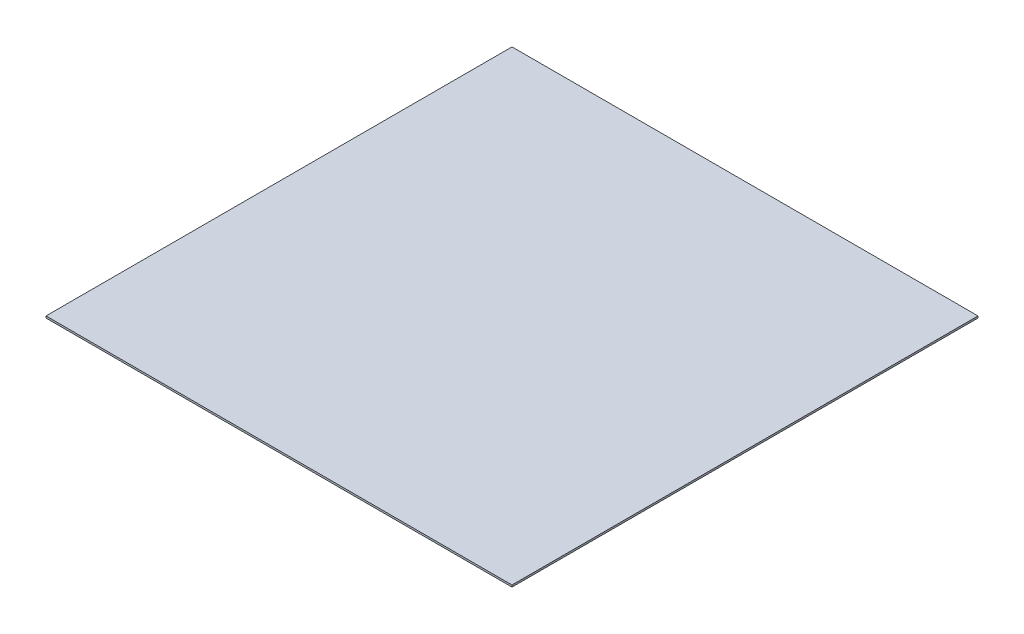
from build123d import *

# Parameters (mm, degrees)
SKETCH1_W           = 5000
SKETCH1_H           = 5000
BOSS_EXTRUDE1_DEPTH = 20


with BuildPart() as part:
    # Sketch1 → Boss-Extrude1 (new body)
    with BuildSketch(Plane(origin=(0, 0, 0), x_dir=(1, 0, 0), z_dir=(0, 1, 0))):
        Rectangle(SKETCH1_W, SKETCH1_H)
    extrude(amount=BOSS_EXTRUDE1_DEPTH)


solid = part.part
